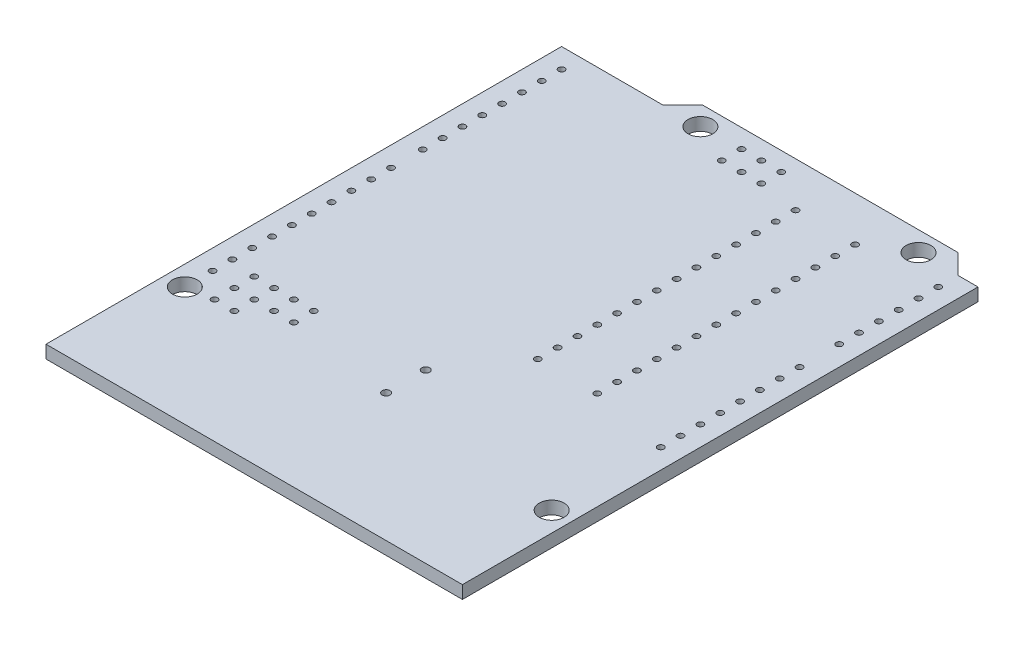
from build123d import *

# Parameters (mm, degrees)
SKETCH1_R             = 1.5875
BOSS_EXTRUDE1_DEPTH   = 1.65
SKETCH2_R             = 0.4
CUT_EXTRUDE1_DEPTH    = 1.65
SKETCH3_R             = 0.4
CUT_EXTRUDE2_DEPTH    = 1.65
LPATTERN1_COUNT       = 15
LPATTERN1_PITCH       = 2.54
SKETCH4_R             = 0.4
CUT_EXTRUDE3_DEPTH    = 1.65
LPATTERN2_COUNT       = 10
LPATTERN2_PITCH       = 2.54
LPATTERN3_COUNT       = 8
LPATTERN3_PITCH       = 2.54
SKETCH5_R             = 0.4
SKETCH5_R_2           = 0.5
CUT_EXTRUDE4_DEPTH    = 10
SKETCH6_R             = 0.4
CUT_EXTRUDE5_DEPTH    = 10
BODY_MOVE_COPY6_ANGLE = 180
BODY_MOVE_COPY7_ANGLE = 180
BODY_MOVE_COPY8_ANGLE = 180
BODY_MOVE_COPY9_ANGLE = 180


with BuildPart() as part:
    # Sketch1 → Boss-Extrude1 (new body)
    with BuildSketch(Plane(origin=(0, 0, 0), x_dir=(1, 0, 0), z_dir=(0, 1, 0))):
        Polygon((0, 0), (-53.34, 0), (-53.34, 66.04), (-40.386, 66.04), (-37.846, 68.58), (-5.08, 68.58), (-2.54, 66.04), (0, 66.04), align=None)
        with Locations((-7.62, 66.04)):
            Circle(SKETCH1_R, mode=Mode.SUBTRACT)
        with Locations((-35.56, 66.04)):
            Circle(SKETCH1_R, mode=Mode.SUBTRACT)
        with Locations((-2.54, 13.97)):
            Circle(SKETCH1_R, mode=Mode.SUBTRACT)
        with Locations((-50.8, 15.24)):
            Circle(SKETCH1_R, mode=Mode.SUBTRACT)
    extrude(amount=-BOSS_EXTRUDE1_DEPTH)

    # Sketch2 → Cut-Extrude1 (cut)
    with BuildSketch(Plane(origin=(0, 0, 0), x_dir=(1, 0, 0), z_dir=(0, 1, 0))):
        with Locations((-2.54, 27.94)):
            Circle(SKETCH2_R)
    cut_extrude1 = extrude(amount=-CUT_EXTRUDE1_DEPTH, mode=Mode.SUBTRACT)

    # Sketch3 → Cut-Extrude2 (cut)
    with BuildSketch(Plane(origin=(0, 0, 0), x_dir=(1, 0, 0), z_dir=(0, 1, 0))):
        with Locations((-50.8, 18.796)):
            Circle(SKETCH3_R)
    cut_extrude2 = extrude(amount=-CUT_EXTRUDE2_DEPTH, mode=Mode.SUBTRACT)

    # LPattern1: Cut-Extrude1 ×15, 1 skipped
    with Locations(*[(0, 0, -i * LPATTERN1_PITCH) for i in range(1, LPATTERN1_COUNT) if i not in (8,)]):
        add(cut_extrude1, mode=Mode.SUBTRACT)

    # Sketch4 → Cut-Extrude3 (cut)
    with BuildSketch(Plane(origin=(0, 0, 0), x_dir=(1, 0, 0), z_dir=(0, 1, 0))):
        with Locations((-50.8, 45.72)):
            Circle(SKETCH4_R)
    cut_extrude3 = extrude(amount=-CUT_EXTRUDE3_DEPTH, mode=Mode.SUBTRACT)

    # LPattern2: Cut-Extrude2 ×10
    with Locations(*[(0, 0, -i * LPATTERN2_PITCH) for i in range(1, LPATTERN2_COUNT)]):
        add(cut_extrude2, mode=Mode.SUBTRACT)

    # LPattern3: Cut-Extrude3 ×8
    with Locations(*[(0, 0, -i * LPATTERN3_PITCH) for i in range(1, LPATTERN3_COUNT)]):
        add(cut_extrude3, mode=Mode.SUBTRACT)

    # Sketch5 → Cut-Extrude4 (cut)
    with BuildSketch(Plane(origin=(0, 0, 0), x_dir=(1, 0, 0), z_dir=(0, 1, 0))):
        with Locations((-30.43, 66.18)):
            Circle(SKETCH5_R)
        with Locations((-27.89, 66.18)):
            Circle(SKETCH5_R)
        with Locations((-25.35, 66.18)):
            Circle(SKETCH5_R)
        with Locations((-25.35, 63.64)):
            Circle(SKETCH5_R)
        with Locations((-27.89, 63.64)):
            Circle(SKETCH5_R)
        with Locations((-30.43, 63.64)):
            Circle(SKETCH5_R)
        with Locations((-47.498, 15.748)):
            Circle(SKETCH5_R)
        with Locations((-47.498, 18.288)):
            Circle(SKETCH5_R)
        with Locations((-47.498, 20.828)):
            Circle(SKETCH5_R)
        with Locations((-44.958, 20.828)):
            Circle(SKETCH5_R)
        with Locations((-44.958, 18.288)):
            Circle(SKETCH5_R)
        with Locations((-44.958, 15.748)):
            Circle(SKETCH5_R)
        with Locations((-42.418, 18.288)):
            Circle(SKETCH5_R)
        with Locations((-42.418, 20.828)):
            Circle(SKETCH5_R)
        with Locations((-39.878, 20.828)):
            Circle(SKETCH5_R)
        with Locations((-39.878, 18.288)):
            Circle(SKETCH5_R)
        with Locations((-26.162, 21.463)):
            Circle(SKETCH5_R_2)
        with Locations((-26.162, 16.383)):
            Circle(SKETCH5_R_2)
    extrude(amount=-CUT_EXTRUDE4_DEPTH, mode=Mode.SUBTRACT)

    # Sketch6 → Cut-Extrude5 (cut)
    with BuildSketch(Plane(origin=(0, 0, 0), x_dir=(1, 0, 0), z_dir=(0, 1, 0))):
        with Locations((-20.193, 29.845)):
            Circle(SKETCH6_R)
        with Locations((-12.573, 29.845)):
            Circle(SKETCH6_R)
        with Locations((-20.193, 32.385)):
            Circle(SKETCH6_R)
        with Locations((-12.573, 32.385)):
            Circle(SKETCH6_R)
        with Locations((-20.193, 34.925)):
            Circle(SKETCH6_R)
        with Locations((-12.573, 34.925)):
            Circle(SKETCH6_R)
        with Locations((-20.193, 37.465)):
            Circle(SKETCH6_R)
        with Locations((-12.573, 37.465)):
            Circle(SKETCH6_R)
        with Locations((-20.193, 40.005)):
            Circle(SKETCH6_R)
        with Locations((-12.573, 40.005)):
            Circle(SKETCH6_R)
        with Locations((-20.193, 42.545)):
            Circle(SKETCH6_R)
        with Locations((-12.573, 42.545)):
            Circle(SKETCH6_R)
        with Locations((-20.193, 45.085)):
            Circle(SKETCH6_R)
        with Locations((-12.573, 45.085)):
            Circle(SKETCH6_R)
        with Locations((-20.193, 47.625)):
            Circle(SKETCH6_R)
        with Locations((-12.573, 47.625)):
            Circle(SKETCH6_R)
        with Locations((-20.193, 50.165)):
            Circle(SKETCH6_R)
        with Locations((-12.573, 50.165)):
            Circle(SKETCH6_R)
        with Locations((-20.193, 52.705)):
            Circle(SKETCH6_R)
        with Locations((-12.573, 52.705)):
            Circle(SKETCH6_R)
        with Locations((-20.193, 55.245)):
            Circle(SKETCH6_R)
        with Locations((-12.573, 55.245)):
            Circle(SKETCH6_R)
        with Locations((-20.193, 57.785)):
            Circle(SKETCH6_R)
        with Locations((-12.573, 57.785)):
            Circle(SKETCH6_R)
        with Locations((-20.193, 60.325)):
            Circle(SKETCH6_R)
        with Locations((-12.573, 60.325)):
            Circle(SKETCH6_R)
        with Locations((-20.193, 62.865)):
            Circle(SKETCH6_R)
        with Locations((-12.573, 62.865)):
            Circle(SKETCH6_R)
    extrude(amount=-CUT_EXTRUDE5_DEPTH, mode=Mode.SUBTRACT)


with BuildPart() as part_1:
    # Body-Move/Copy1: moved
    add(part.part.moved(Location((50, 0, 0))))


with BuildPart() as part_2:
    # Body-Move/Copy2: moved
    add(part_1.part.moved(Location((20, -240, 0))))


with BuildPart() as part_3:
    # Body-Move/Copy6: moved
    add(part_2.part.rotate(Axis((43.33, 0, -34.29), (0, 1, 0)), BODY_MOVE_COPY6_ANGLE))


with BuildPart() as part_4:
    # Body-Move/Copy7: moved
    add(part_3.part.rotate(Axis((43.33, 0, -34.29), (0, 1, 0)), BODY_MOVE_COPY7_ANGLE))


with BuildPart() as part_5:
    # Body-Move/Copy8: moved
    add(part_4.part.rotate(Axis((43.33, 0, -34.29), (0, 1, 0)), BODY_MOVE_COPY8_ANGLE))


with BuildPart() as part_6:
    # Body-Move/Copy9: moved
    add(part_5.part.rotate(Axis((43.33, 0, -34.29), (0, 1, 0)), BODY_MOVE_COPY9_ANGLE))


solid = part_6.part
